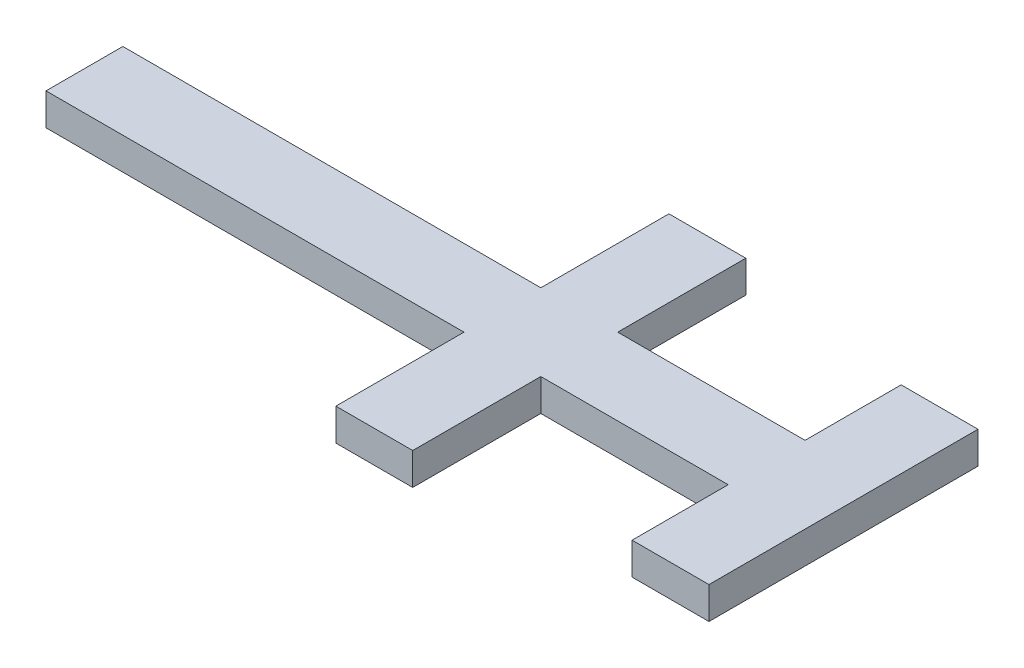
from build123d import *

# Parameters (mm, degrees)
SKETCH_3_W           = 10
SKETCH_3_H           = 40
SKETCH_3_W_2         = 31.25
SKETCH_3_H_2         = 10
SKETCH_3_W_3         = 40.25
SKETCH_3_W_4         = 25
EXTRUDE_1_DEPTH      = 1
EXTRUDE_2_DEPTH      = 4
EXTRUDE_2_DEPTH_BACK = 1
SKETCH_5_W           = 25
SKETCH_5_H           = 10
SKETCH_5_W_2         = 10
SKETCH_5_H_2         = 40
EXTRUDE_3_DEPTH      = 2


with BuildPart() as part:
    # 草图3 → 凸台-拉伸1 (new body)
    with BuildSketch(Plane(origin=(0, 0, 0), x_dir=(1, 0, 0), z_dir=(0, 1, 0))):
        with Locations((20.5, 0)):
            Rectangle(SKETCH_3_W, SKETCH_3_H)
        with Locations((-0.125, 0)):
            Rectangle(SKETCH_3_W_2, SKETCH_3_H_2)
        Polygon((-15.75, -5), (-15.75, 5), (-15.75, 25), (-25.75, 25), (-25.75, 5), (-25.75, -5), (-25.75, -25), (-15.75, -25), align=None)
        with Locations((-45.875, 0)):
            Rectangle(SKETCH_3_W_3, SKETCH_3_H_2)
        with Locations((-78.5, 0)):
            Rectangle(SKETCH_3_W_4, SKETCH_3_H_2)
    extrude(amount=EXTRUDE_1_DEPTH)

    # 草图4 → 凸台-拉伸2 (add, two sides)
    with BuildSketch(Plane.XZ) as extrude_2_sk:
        Polygon((14.5, -21), (26.5, -21), (26.5, 21), (14.5, 21), (14.5, 6), (-14.75, 6), (-14.75, 26), (-26.75, 26), (-26.75, 6), (-92, 6), (-92, -6), (-26.75, -6), (-26.75, -26), (-14.75, -26), (-14.75, -6), (14.5, -6), align=None)
        Polygon((15.5, -20), (25.5, -20), (25.5, 20), (15.5, 20), (15.5, 5), (-15.75, 5), (-15.75, 25), (-25.75, 25), (-25.75, 5), (-91, 5), (-91, -5), (-25.75, -5), (-25.75, -25), (-15.75, -25), (-15.75, -5), (15.5, -5), align=None, mode=Mode.SUBTRACT)
    extrude(amount=EXTRUDE_2_DEPTH)
    extrude(extrude_2_sk.sketch, amount=-EXTRUDE_2_DEPTH_BACK)

    # 草图5 → 凸台-拉伸3 (add)
    with BuildSketch(Plane.XZ):
        Polygon((-25.75, 25), (-25.75, 5), (-26, 5), (-26, -5), (-25.75, -5), (-25.75, -25), (-15.75, -25), (-15.75, -5), (-15.5, -5), (-15.5, 5), (-15.75, 5), (-15.75, 25), align=None)
        with Locations((-78.5, 0)):
            Rectangle(SKETCH_5_W, SKETCH_5_H)
        with Locations((20.5, 0)):
            Rectangle(SKETCH_5_W_2, SKETCH_5_H_2)
    extrude(amount=EXTRUDE_3_DEPTH)


solid = part.part
